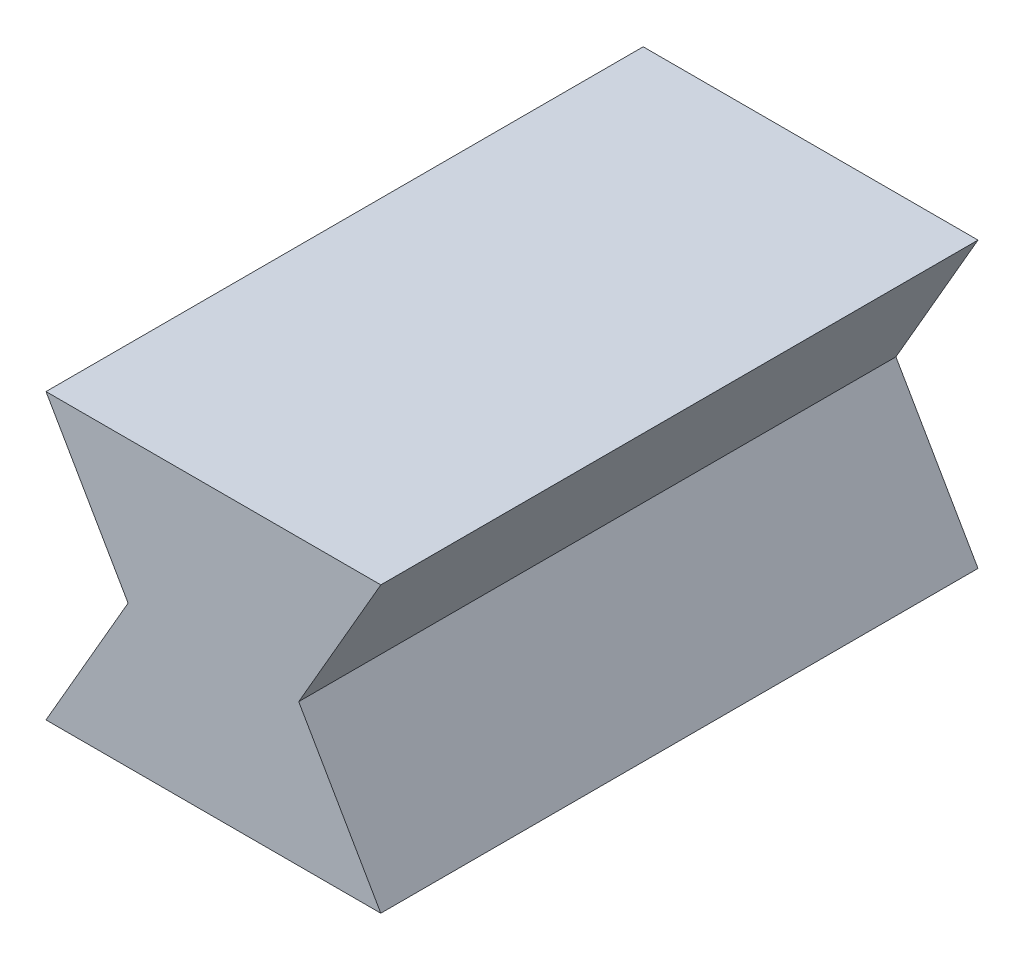
from build123d import *

# Parameters (mm, degrees)
EXTRUDE2_DEPTH = 10.5


with BuildPart() as part:
    # Sketch1 → Extrude2 (new body, symmetric)
    with BuildSketch(Plane.XY):
        Polygon((3, 0), (5.886751346, -5), (-5.886751346, -5), (-3, 0), (-5.886751346, 5), (5.886751346, 5), align=None)
    extrude(amount=EXTRUDE2_DEPTH, both=True)


solid = part.part
